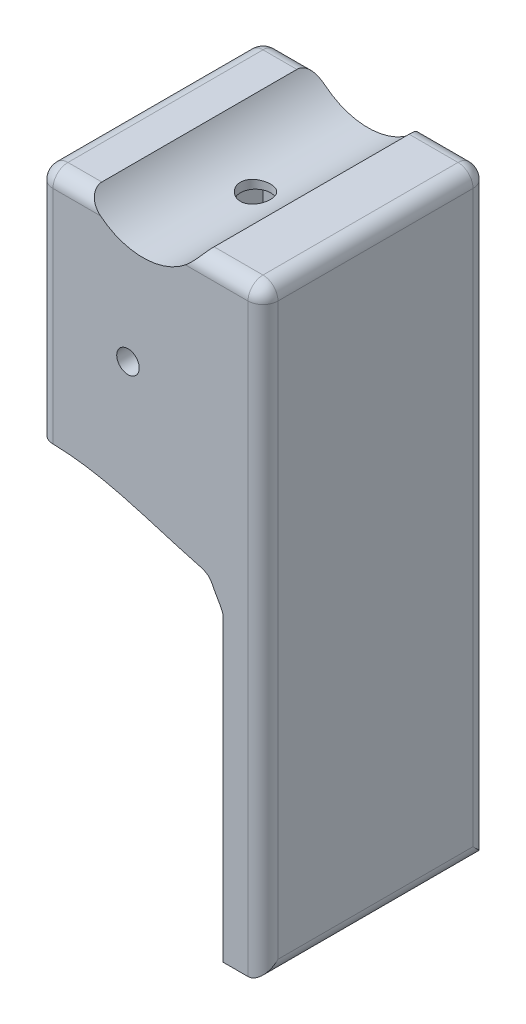
from build123d import *

# Parameters (mm, degrees)
CROQUIS1_W              = 28
CROQUIS1_H              = 30
SALIENTE_EXTRUIR1_DEPTH = 30
CROQUIS2_W              = 22
CROQUIS2_H              = 24
CORTAR_EXTRUIR1_DEPTH   = 25
CORTAR_EXTRUIR3_START   = -30
CORTAR_EXTRUIR3_DEPTH   = 30
CROQUIS3_R              = 2
CORTAR_EXTRUIR4_DEPTH   = 5
CORTAR_EXTRUIR5_START   = -30
CROQUIS6_R              = 1.5
CORTAR_EXTRUIR5_DEPTH   = 30
CROQUIS8_W              = 30
CROQUIS8_H              = 78
SALIENTE_EXTRUIR2_DEPTH = 2
CROQUIS9_W              = 3.3
CROQUIS9_H              = 3
SALIENTE_EXTRUIR3_DEPTH = 48
CROQUIS10_W             = 30
CROQUIS10_H             = 2
SALIENTE_EXTRUIR4_DEPTH = 5.3
CROQUIS11_W             = 24
CROQUIS11_H             = 48
CORTAR_EXTRUIR6_DEPTH   = 1
SALIENTE_EXTRUIR5_DEPTH = 3
REDONDEO2_R             = 2


with BuildPart() as part:
    # Croquis1 → Saliente-Extruir1 (new body)
    with BuildSketch(Plane.XY):
        with Locations((-25.946619217, -0.658362989)):
            Rectangle(CROQUIS1_W, CROQUIS1_H)
    extrude(amount=SALIENTE_EXTRUIR1_DEPTH)

    # Croquis2 → Cortar-Extruir1 (cut)
    with BuildSketch(Plane.XZ.offset(15.658362989)):
        with Locations((-25.946619217, 15)):
            Rectangle(CROQUIS2_W, CROQUIS2_H)
    extrude(amount=-CORTAR_EXTRUIR1_DEPTH, mode=Mode.SUBTRACT)

    # Croquis5 → Cortar-Extruir3 (cut)
    with BuildSketch(Plane.XY.offset(30).offset(CORTAR_EXTRUIR3_START)):
        with BuildLine():
            Line((-18.463304444, 14.341637011), (-33.429933991, 14.341637011))
            ThreePointArc((-33.429933991, 14.341637011), (-25.946619217, 10.341637011), (-18.463304444, 14.341637011))
        make_face()
    extrude(amount=CORTAR_EXTRUIR3_DEPTH, mode=Mode.SUBTRACT)

    # Croquis3 → Cortar-Extruir4 (cut)
    with BuildSketch(Plane.XZ.offset(-9.341637011)):
        with Locations((-25.946619217, 15)):
            Circle(CROQUIS3_R)
    extrude(amount=-CORTAR_EXTRUIR4_DEPTH, mode=Mode.SUBTRACT)

    # Croquis6 → Cortar-Extruir5 (cut)
    with BuildSketch(Plane.XY.offset(30).offset(CORTAR_EXTRUIR5_START)):
        with Locations((-27.946619217, -2.658362989)):
            Circle(CROQUIS6_R)
    extrude(amount=CORTAR_EXTRUIR5_DEPTH, mode=Mode.SUBTRACT)

    # Croquis8 → Saliente-Extruir2 (add)
    with BuildSketch(Plane(origin=(-11.946619217, 0, 0), x_dir=(0, 0, -1), z_dir=(1, 0, 0))):
        with Locations((-15, -24.658362989)):
            Rectangle(CROQUIS8_W, CROQUIS8_H)
    extrude(amount=SALIENTE_EXTRUIR2_DEPTH)

    # Croquis9 → Saliente-Extruir3 (add)
    with BuildSketch(Plane.XZ.offset(15.658362989)):
        with Locations((-13.596619217, 1.5)):
            Rectangle(CROQUIS9_W, CROQUIS9_H)
        with Locations((-13.596619217, 28.5)):
            Rectangle(CROQUIS9_W, CROQUIS9_H)
    extrude(amount=SALIENTE_EXTRUIR3_DEPTH)

    # Croquis10 → Saliente-Extruir4 (add)
    with BuildSketch(Plane(origin=(-9.946619217, 0, 0), x_dir=(0, 0, -1), z_dir=(1, 0, 0))):
        with Locations((-15, -64.658362989)):
            Rectangle(CROQUIS10_W, CROQUIS10_H)
    extrude(amount=-SALIENTE_EXTRUIR4_DEPTH)

    # Croquis11 → Cortar-Extruir6 (cut)
    with BuildSketch(Plane.ZY.offset(11.946619217)):
        with Locations((15, -39.658362989)):
            Rectangle(CROQUIS11_W, CROQUIS11_H)
    extrude(amount=-CORTAR_EXTRUIR6_DEPTH, mode=Mode.SUBTRACT)

    # Croquis12 → Saliente-Extruir5 (add)
    with BuildSketch(Plane.XY.offset(30)):
        with BuildLine():
            Line((-15.246619217, -15.658362989), (-15.246619217, -24.658362989))
            Line((-15.246619217, -24.658362989), (-15.246619217, -25.658362989))
            add(Edge.make_bspline(
                [(-15.246619217, -25.658362989), (-15.454297932, -24.784354335), (-16.276669262, -23.769291156), (-17.060396799, -21.819515511), (-25.742756364, -19.637986616), (-31.719204445, -16.94099226), (-39.946619217, -17.158362989)],
                knots=[0, 0, 0, 0, 0.094483023, 0.145649735, 0.216240506, 1, 1, 1, 1], degree=3))
            Line((-39.946619217, -17.158362989), (-39.946619217, -15.658362989))
            Line((-39.946619217, -15.658362989), (-15.246619217, -15.658362989))
        make_face()
    saliente_extruir5 = extrude(amount=-SALIENTE_EXTRUIR5_DEPTH)

    # Simetría2: Saliente-Extruir5 across plane
    add(saliente_extruir5.mirror(Plane(origin=(0, 0, 15), x_dir=(1, 0, 0), z_dir=(0, 0, -1))))

    # Redondeo2
    redondeo2_edges = [part.edges().sort_by_distance(p)[0] for p in [
        (-14.20496183, 14.341637011, 30),
        (-36.688276604, 14.341637011, 0),
        (-36.688276604, 14.341637011, 30),
        (-39.946619217, -1.408362989, 30),
        (-14.20496183, 14.341637011, 0),
        (-9.946619217, -25.658362989, 30),
        (-9.946619217, -25.658362989, 0),
        (-9.946619217, 14.341637011, 15),
        (-39.946619217, -1.408362989, 0),
        (-39.946619217, 14.341637011, 15),
        (-9.946619217, -65.658362989, 15),
    ]]
    fillet(redondeo2_edges, radius=REDONDEO2_R)


solid = part.part
